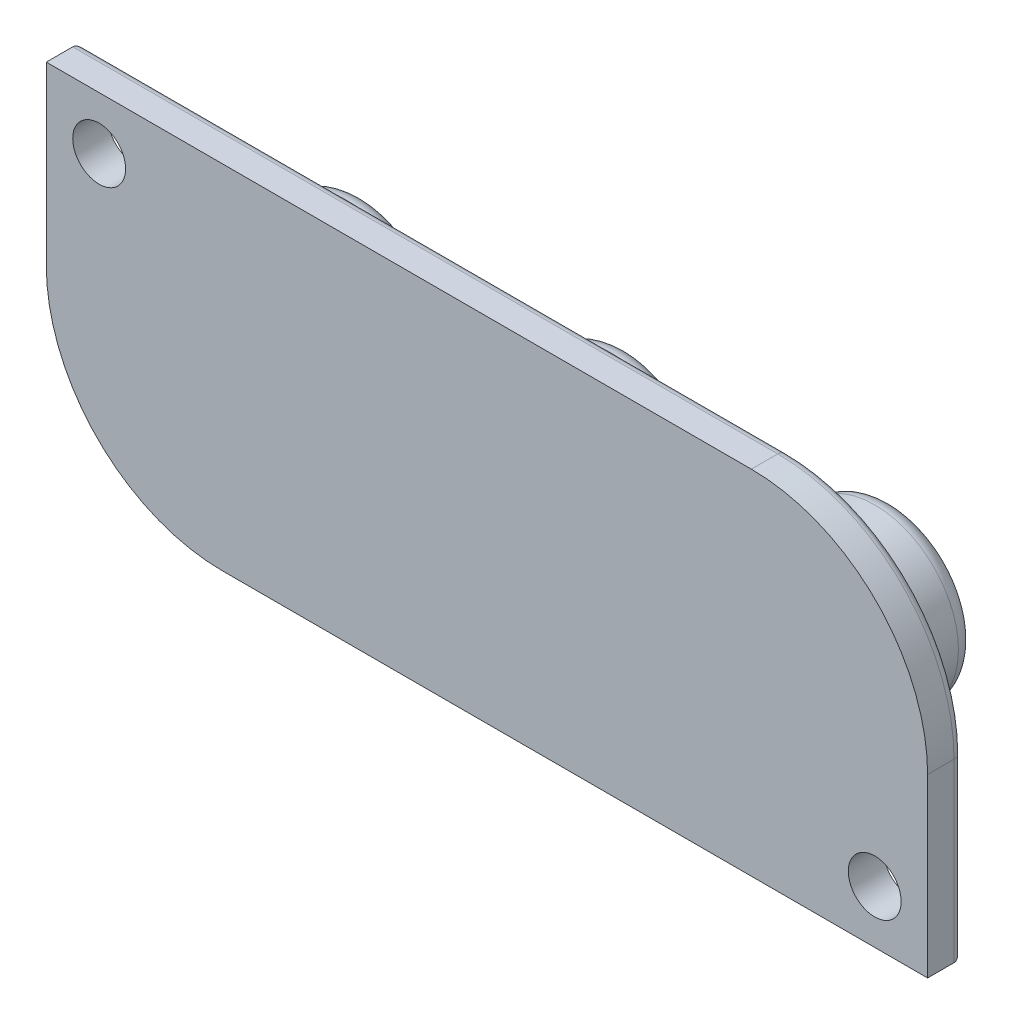
from build123d import *

# Parameters (mm, degrees)
CROQUIS1_W              = 50
CROQUIS1_H              = 20
SALIENTE_EXTRUIR1_DEPTH = 2
CROQUIS2_R              = 4.75
SALIENTE_EXTRUIR2_DEPTH = 6
REDONDEO1_R             = 10
CROQUIS10_R             = 1.5
CORTAR_EXTRUIR5_DEPTH   = 2
SALIENTE_EXTRUIR4_DEPTH = 0.5
REDONDEO2_R             = 2
REDONDEO3_R             = 0.5
REDONDEO4_R             = 1


with BuildPart() as part:
    # Croquis1 → Saliente-Extruir1 (new body)
    with BuildSketch(Plane.XY):
        with Locations((77.5, 27.5)):
            Rectangle(CROQUIS1_W, CROQUIS1_H)
    extrude(amount=SALIENTE_EXTRUIR1_DEPTH)

    # Croquis2 → Saliente-Extruir2 (add)
    with BuildSketch(Plane(origin=(0, 0, 0), x_dir=(-1, 0, 0), z_dir=(0, 0, -1))):
        with Locations((-92.5, 27.5)):
            Circle(CROQUIS2_R)
        with Locations((-77.5, 27.5)):
            Circle(CROQUIS2_R)
        with Locations((-62.5, 27.5)):
            Circle(CROQUIS2_R)
    extrude(amount=SALIENTE_EXTRUIR2_DEPTH)

    # Redondeo1
    redondeo1_edges = [part.edges().sort_by_distance(p)[0] for p in [
        (52.5, 17.5, 1),
        (102.5, 37.5, 1),
    ]]
    fillet(redondeo1_edges, radius=REDONDEO1_R)

    # Croquis10 → Cortar-Extruir5 (cut)
    with BuildSketch(Plane.XY.offset(2)):
        with Locations((99.5, 20.5)):
            Circle(CROQUIS10_R)
        with Locations((55.5, 34.5)):
            Circle(CROQUIS10_R)
    extrude(amount=-CORTAR_EXTRUIR5_DEPTH, mode=Mode.SUBTRACT)

    # Croquis12 → Saliente-Extruir4 (add)
    with BuildSketch(Plane(origin=(0, 0, -6), x_dir=(-1, 0, 0), z_dir=(0, 0, -1))):
        Polygon((-65.728582378, 27.617760721), (-60.958012758, 29.751858822), (-60.314223201, 29.111036038), (-62.427553897, 24.327610405), (-63.076288074, 24.974366734), (-62.488867188, 26.212499645), (-63.868416239, 27.587104075), (-65.104571302, 26.995727493), align=None)
        Polygon((-61.24183396, 28.848971164), (-63.245394087, 27.882792367), (-62.190212125, 26.830577177), (-61.2270001, 28.834137303), align=None, mode=Mode.SUBTRACT)
        with BuildLine():
            Line((-80.194104158, 27.217246481), (-76.74968169, 30.673536038))
            Line((-76.74968169, 30.673536038), (-75.069499728, 28.99928762))
            add(Edge.make_bspline(
                [(-75.069499728, 28.99928762), (-75.031406907, 28.959869805), (-74.957198808, 28.883080504), (-74.85725848, 28.763013024), (-74.769481382, 28.643121267), (-74.694794468, 28.522404001), (-74.634041008, 28.400607841), (-74.587719334, 28.278103073), (-74.552006431, 28.155992502), (-74.531457849, 28.033206264), (-74.524003268, 27.911119096), (-74.532026735, 27.790867413), (-74.554624799, 27.672672956), (-74.594577171, 27.557415166), (-74.646430642, 27.442885428), (-74.715918443, 27.332359673), (-74.798529925, 27.222991059), (-74.863080561, 27.155308069), (-74.896438019, 27.120331924)],
                knots=[0, 0, 0, 0, 0.000164402, 0.00032027, 0.000468229, 0.000609853, 0.000745627, 0.000875843, 0.001002309, 0.001126682, 0.001248516, 0.001368437, 0.001487326, 0.001608351, 0.001733574, 0.001863666, 0.001999152, 0.002144039, 0.002144039, 0.002144039, 0.002144039], degree=3))
            add(Edge.make_bspline(
                [(-74.896438019, 27.120331924), (-74.939852018, 27.079463327), (-75.023797155, 27.000439971), (-75.164643934, 26.906226208), (-75.310808548, 26.836820345), (-75.463612719, 26.79366792), (-75.621895796, 26.775903113), (-75.78562761, 26.783249402), (-75.955083291, 26.816604384), (-76.06613128, 26.856418859), (-76.123692766, 26.877056607)],
                knots=[0, 0, 0, 0, 0.000178623, 0.000345385, 0.000505975, 0.000662191, 0.000819451, 0.000981783, 0.001152067, 0.001335325, 0.001335325, 0.001335325, 0.001335325], degree=3))
            Line((-76.123692766, 26.877056607), (-76.133582006, 26.867167367))
            add(Edge.make_bspline(
                [(-76.133582006, 26.867167367), (-76.11369622, 26.834790241), (-76.074673108, 26.771254599), (-76.024712839, 26.673453892), (-75.986460519, 26.574768218), (-75.955922132, 26.477192217), (-75.9375611, 26.379250027), (-75.927133374, 26.282317931), (-75.927382868, 26.18523505), (-75.936778042, 26.088309081), (-75.958573722, 25.991919081), (-75.987753069, 25.89564402), (-76.028257606, 25.800481135), (-76.076554674, 25.704739447), (-76.136522338, 25.609945597), (-76.205809116, 25.515348193), (-76.284232508, 25.420382704), (-76.342784715, 25.360296437), (-76.372901626, 25.329390468)],
                knots=[0, 0, 0, 0, 0.000113971, 0.000223653, 0.000328879, 0.000431179, 0.000529898, 0.000627316, 0.000723241, 0.000820659, 0.000918807, 0.001019216, 0.001122064, 0.001228652, 0.001340606, 0.001458101, 0.001580288, 0.001709701, 0.001709701, 0.001709701, 0.001709701], degree=3))
            add(Edge.make_bspline(
                [(-76.372901626, 25.329390468), (-76.408461875, 25.29528593), (-76.47821672, 25.228386602), (-76.59264877, 25.143795796), (-76.70985266, 25.072500255), (-76.831291433, 25.016703203), (-76.956427812, 24.975928607), (-77.085482321, 24.950041076), (-77.21830116, 24.938620269), (-77.307764218, 24.943317011), (-77.352925361, 24.945687936)],
                knots=[0, 0, 0, 0, 0.000147681, 0.000289691, 0.000425879, 0.000558631, 0.000689666, 0.000819803, 0.000952764, 0.001088304, 0.001088304, 0.001088304, 0.001088304], degree=3))
            add(Edge.make_bspline(
                [(-77.352925361, 24.945687936), (-77.404574561, 24.951670485), (-77.509103747, 24.963778145), (-77.6645096, 25.006091539), (-77.820257286, 25.065947907), (-77.976931065, 25.143813749), (-78.134781623, 25.23927965), (-78.292653112, 25.353624165), (-78.451814459, 25.485549908), (-78.553479056, 25.584139987), (-78.605892133, 25.634968)],
                knots=[0, 0, 0, 0, 0.000155799, 0.00031531, 0.000481523, 0.000655776, 0.000839452, 0.00103431, 0.001240066, 0.001459029, 0.001459029, 0.001459029, 0.001459029], degree=3))
            Line((-78.605892133, 25.634968), (-80.194104158, 27.217246481))
        make_face()
        with BuildLine():
            Line((-78.020449095, 28.187380974), (-79.097387386, 27.107475911))
            Line((-79.097387386, 27.107475911), (-78.027371563, 26.041415784))
            add(Edge.make_bspline(
                [(-78.027371563, 26.041415784), (-78.003692834, 26.018242129), (-77.957888215, 25.973414534), (-77.884787626, 25.915056154), (-77.813013156, 25.864465073), (-77.741467308, 25.82221442), (-77.669705624, 25.789640552), (-77.598530707, 25.764053831), (-77.526916019, 25.7493305), (-77.455907848, 25.743586742), (-77.385043333, 25.744837015), (-77.31453407, 25.75768903), (-77.243983915, 25.77704161), (-77.174211174, 25.806482022), (-77.104812837, 25.844008761), (-77.036296808, 25.891605417), (-76.96688198, 25.946401409), (-76.923357209, 25.988910844), (-76.900987069, 26.010759139)],
                knots=[0, 0, 0, 0, 9.9336e-05, 0.000192158, 0.000280223, 0.000362654, 0.000440979, 0.000516352, 0.000589083, 0.000659547, 0.000729788, 0.000800998, 0.000873944, 0.000948874, 0.001027641, 0.001110203, 0.001198854, 0.001292598, 0.001292598, 0.001292598, 0.001292598], degree=3))
            add(Edge.make_bspline(
                [(-76.900987069, 26.010759139), (-76.879808073, 26.032478317), (-76.838632428, 26.074704169), (-76.785474447, 26.142242993), (-76.740091453, 26.209676479), (-76.704692869, 26.278300266), (-76.676411136, 26.34658383), (-76.657276966, 26.415635707), (-76.647378142, 26.485090242), (-76.646244482, 26.554907426), (-76.654729219, 26.624848047), (-76.670341325, 26.695295789), (-76.695376198, 26.765957898), (-76.729862897, 26.836275415), (-76.770999509, 26.908178467), (-76.823535062, 26.978797828), (-76.882378271, 27.051597043), (-76.927290902, 27.097610995), (-76.950433272, 27.121320848)],
                knots=[0, 0, 0, 0, 9.0949e-05, 0.00017682, 0.000257458, 0.000334423, 0.000408063, 0.000478839, 0.000548766, 0.000617998, 0.000687673, 0.000759648, 0.000834087, 0.000911936, 0.000994367, 0.001082198, 0.001175645, 0.001274981, 0.001274981, 0.001274981, 0.001274981], degree=3))
            Line((-76.950433272, 27.121320848), (-78.020449095, 28.187380974))
        make_face(mode=Mode.SUBTRACT)
        with BuildLine():
            Line((-76.635955424, 29.576819265), (-77.586311436, 28.623496481))
            Line((-77.586311436, 28.623496481), (-76.59837631, 27.63951705))
            add(Edge.make_bspline(
                [(-76.59837631, 27.63951705), (-76.561613064, 27.605410197), (-76.490405309, 27.539347684), (-76.367723814, 27.467152773), (-76.240731691, 27.417591371), (-76.13029606, 27.398873724), (-76.041778589, 27.399132549), (-75.976304774, 27.405620398), (-75.91198445, 27.421015661), (-75.84925073, 27.443483484), (-75.787782628, 27.474042972), (-75.727572252, 27.511421673), (-75.668780442, 27.557416206), (-75.632216186, 27.592692523), (-75.613407955, 27.610838253)],
                knots=[0, 0, 0, 0, 0.000150063, 0.00029066, 0.000424, 0.000557314, 0.000623572, 0.000689207, 0.000754213, 0.000821468, 0.000888693, 0.000959764, 0.001033749, 0.001112118, 0.001112118, 0.001112118, 0.001112118], degree=3))
            add(Edge.make_bspline(
                [(-75.613407955, 27.610838253), (-75.577668041, 27.649570472), (-75.510273372, 27.722607722), (-75.435968576, 27.844923514), (-75.390976397, 27.968344839), (-75.379750616, 28.094693465), (-75.400796761, 28.221450711), (-75.45345368, 28.347993989), (-75.536972318, 28.474431834), (-75.609468209, 28.551732597), (-75.648020297, 28.592839835)],
                knots=[0, 0, 0, 0, 0.000157785, 0.000297535, 0.000426392, 0.000548515, 0.000673703, 0.000808127, 0.000956795, 0.001125647, 0.001125647, 0.001125647, 0.001125647], degree=3))
            Line((-75.648020297, 28.592839835), (-76.635955424, 29.576819265))
        make_face(mode=Mode.SUBTRACT)
        with BuildLine():
            Line((-90.685693514, 26.645648379), (-91.290915033, 27.24889205))
            add(Edge.make_bspline(
                [(-91.290915033, 27.24889205), (-91.270582788, 27.284201993), (-91.230813835, 27.353266645), (-91.181685871, 27.459729499), (-91.140646572, 27.564217123), (-91.110026776, 27.667534568), (-91.087815863, 27.769301673), (-91.074768781, 27.869874732), (-91.071616725, 27.969263518), (-91.078817729, 28.066936619), (-91.094778839, 28.163222263), (-91.119166003, 28.258507454), (-91.154621319, 28.351822291), (-91.197800924, 28.444226251), (-91.252075773, 28.534299637), (-91.31455063, 28.623745845), (-91.38662045, 28.71171996), (-91.440488341, 28.767268784), (-91.467932438, 28.795569265)],
                knots=[0, 0, 0, 0, 0.000122179, 0.000238977, 0.000351371, 0.000458691, 0.000561881, 0.000663567, 0.000762504, 0.000859665, 0.000956887, 0.00105499, 0.001154184, 0.001255928, 0.001360572, 0.001469214, 0.001583048, 0.001701277, 0.001701277, 0.001701277, 0.001701277], degree=3))
            add(Edge.make_bspline(
                [(-91.467932438, 28.795569265), (-91.511194221, 28.836529053), (-91.595486332, 28.916335911), (-91.734705657, 29.015736435), (-91.878644099, 29.096140789), (-92.029219567, 29.154622136), (-92.18502764, 29.193708834), (-92.346187137, 29.212444863), (-92.513071547, 29.210687732), (-92.624449343, 29.193821026), (-92.681342248, 29.185205341)],
                knots=[0, 0, 0, 0, 0.000178547, 0.000347884, 0.000511655, 0.000671976, 0.000830996, 0.0009923, 0.001157462, 0.001329924, 0.001329924, 0.001329924, 0.001329924], degree=3))
            add(Edge.make_bspline(
                [(-92.681342248, 29.185205341), (-92.731688699, 29.174605566), (-92.832970013, 29.153282132), (-92.981745611, 29.103808089), (-93.128324244, 29.041127455), (-93.273375115, 28.965801407), (-93.416119044, 28.875935146), (-93.557556185, 28.773298289), (-93.69629142, 28.655835202), (-93.785119308, 28.570269196), (-93.830471995, 28.526581924)],
                knots=[0, 0, 0, 0, 0.00015425, 0.000310303, 0.000469372, 0.000632145, 0.000800076, 0.000974937, 0.001156005, 0.001344892, 0.001344892, 0.001344892, 0.001344892], degree=3))
            add(Edge.make_bspline(
                [(-93.830471995, 28.526581924), (-93.874299585, 28.481344137), (-93.96016923, 28.392711548), (-94.075681621, 28.252325122), (-94.179436236, 28.111506763), (-94.267221713, 27.967322008), (-94.343326254, 27.822281201), (-94.405756177, 27.67530406), (-94.453969479, 27.525936108), (-94.475443521, 27.42480602), (-94.48612864, 27.374485405)],
                knots=[0, 0, 0, 0, 0.000188887, 0.000370079, 0.00054494, 0.00071319, 0.000875964, 0.001035944, 0.001191692, 0.001345942, 0.001345942, 0.001345942, 0.001345942], degree=3))
            add(Edge.make_bspline(
                [(-94.48612864, 27.374485405), (-94.494452105, 27.317580367), (-94.510751953, 27.206143184), (-94.511020389, 27.039354925), (-94.493041987, 26.878006092), (-94.452385348, 26.722810491), (-94.394135977, 26.572232928), (-94.312510478, 26.429124314), (-94.213380745, 26.289576414), (-94.13352285, 26.205312057), (-94.092536868, 26.162064519)],
                knots=[0, 0, 0, 0, 0.00017234, 0.000337493, 0.000498797, 0.00065806, 0.000817461, 0.000981711, 0.001151048, 0.001329595, 0.001329595, 0.001329595, 0.001329595], degree=3))
            add(Edge.make_bspline(
                [(-94.092536868, 26.162064519), (-94.060126396, 26.131426446), (-93.996745113, 26.071511232), (-93.89399339, 25.994057881), (-93.788074653, 25.928810011), (-93.677356586, 25.878847593), (-93.564150943, 25.838959493), (-93.446369009, 25.815199833), (-93.325460281, 25.80096894), (-93.243744635, 25.8036898), (-93.202505223, 25.805062936)],
                knots=[0, 0, 0, 0, 0.00013371, 0.00026148, 0.000385289, 0.000506092, 0.000625244, 0.000744527, 0.000865859, 0.000989478, 0.000989478, 0.000989478, 0.000989478], degree=3))
            add(Edge.make_bspline(
                [(-93.202505223, 25.805062936), (-93.164180217, 25.808326331), (-93.087699662, 25.814838692), (-92.9737791, 25.837160931), (-92.860887833, 25.870306547), (-92.748051791, 25.912366857), (-92.63656614, 25.966674081), (-92.526079975, 26.031124859), (-92.415878047, 26.105249665), (-92.345398649, 26.16124076), (-92.309506805, 26.189754392)],
                knots=[0, 0, 0, 0, 0.000115327, 0.000230145, 0.000347511, 0.000468001, 0.000590962, 0.000719023, 0.000851502, 0.000988977, 0.000988977, 0.000988977, 0.000988977], degree=3))
            Line((-92.309506805, 26.189754392), (-91.718130223, 25.600355658))
            add(Edge.make_bspline(
                [(-91.718130223, 25.600355658), (-91.772972311, 25.553412854), (-91.880646783, 25.461247479), (-92.054183568, 25.344504773), (-92.22911169, 25.24298529), (-92.409726041, 25.162721963), (-92.593976904, 25.099995543), (-92.782428411, 25.055960234), (-92.975033443, 25.032825508), (-93.169744559, 25.026206281), (-93.364093447, 25.040690174), (-93.555107501, 25.071763675), (-93.740897231, 25.123314208), (-93.920757349, 25.195881468), (-94.096380797, 25.284651732), (-94.266294903, 25.393279817), (-94.430350475, 25.521699584), (-94.532727115, 25.618927468), (-94.585021045, 25.668591417)],
                knots=[0, 0, 0, 0, 0.000216396, 0.000424862, 0.000626394, 0.000822495, 0.0010167, 0.001209568, 0.0014019, 0.001597797, 0.001793107, 0.001985599, 0.002177545, 0.002370182, 0.00256655, 0.00276709, 0.002974212, 0.003190479, 0.003190479, 0.003190479, 0.003190479], degree=3))
            add(Edge.make_bspline(
                [(-94.585021045, 25.668591417), (-94.645113638, 25.731315989), (-94.762768419, 25.854123901), (-94.912021768, 26.05570633), (-95.037233506, 26.263276005), (-95.135853997, 26.479255802), (-95.208407046, 26.702928919), (-95.255209808, 26.934084824), (-95.275725437, 27.173138802), (-95.268220109, 27.33426432), (-95.264411868, 27.416020215)],
                knots=[0, 0, 0, 0, 0.000260371, 0.000509778, 0.000750609, 0.000986483, 0.001220409, 0.0014545, 0.001692665, 0.00193799, 0.00193799, 0.00193799, 0.00193799], degree=3))
            add(Edge.make_bspline(
                [(-95.264411868, 27.416020215), (-95.256780963, 27.494382278), (-95.241592663, 27.650351522), (-95.190416338, 27.879575515), (-95.120483561, 28.103744925), (-95.02699161, 28.32153589), (-94.911291137, 28.533460176), (-94.773679663, 28.739101697), (-94.617134586, 28.941497527), (-94.496907228, 29.066288379), (-94.435693514, 29.129825594)],
                knots=[0, 0, 0, 0, 0.000236005, 0.000469737, 0.00070306, 0.00093965, 0.001179503, 0.001426354, 0.001681354, 0.001945861, 0.001945861, 0.001945861, 0.001945861], degree=3))
            add(Edge.make_bspline(
                [(-94.435693514, 29.129825594), (-94.371630317, 29.19112322), (-94.245873767, 29.311450933), (-94.04558347, 29.472226539), (-93.839068375, 29.610492353), (-93.626662558, 29.72679747), (-93.408680841, 29.821564308), (-93.184484124, 29.892371961), (-92.955352483, 29.944875995), (-92.799278603, 29.959899533), (-92.72089921, 29.967444265)],
                knots=[0, 0, 0, 0, 0.000265905, 0.000521973, 0.000769372, 0.001010566, 0.001247547, 0.00148117, 0.001715113, 0.001951118, 0.001951118, 0.001951118, 0.001951118], degree=3))
            add(Edge.make_bspline(
                [(-92.72089921, 29.967444265), (-92.639473874, 29.971252669), (-92.479008395, 29.978757918), (-92.240599719, 29.958215293), (-92.010267969, 29.911307856), (-91.786618332, 29.83998431), (-91.570990014, 29.740899686), (-91.362661006, 29.616420769), (-91.161307718, 29.466743689), (-91.038231114, 29.34972429), (-90.975448261, 29.290031291)],
                knots=[0, 0, 0, 0, 0.000244336, 0.000481515, 0.000715606, 0.000948287, 0.001184162, 0.001425842, 0.001675249, 0.001934952, 0.001934952, 0.001934952, 0.001934952], degree=3))
            add(Edge.make_bspline(
                [(-90.975448261, 29.290031291), (-90.927523774, 29.240636047), (-90.833728064, 29.143961835), (-90.708548386, 28.989143785), (-90.598600573, 28.831257487), (-90.504275048, 28.66959064), (-90.425011673, 28.504480647), (-90.363502177, 28.334958926), (-90.314073174, 28.162390089), (-90.296132119, 28.044576576), (-90.287157121, 27.985640468)],
                knots=[0, 0, 0, 0, 0.000206382, 0.000403922, 0.000596498, 0.000783072, 0.000964876, 0.001145093, 0.001323594, 0.001502272, 0.001502272, 0.001502272, 0.001502272], degree=3))
            add(Edge.make_bspline(
                [(-90.287157121, 27.985640468), (-90.281302599, 27.924721121), (-90.269766622, 27.804683301), (-90.274077752, 27.625250994), (-90.297002717, 27.450311675), (-90.33762057, 27.279574297), (-90.396405113, 27.113060742), (-90.474068848, 26.951370915), (-90.570442512, 26.79410071), (-90.646817987, 26.695723107), (-90.685693514, 26.645648379)],
                knots=[0, 0, 0, 0, 0.000183474, 0.000361524, 0.000537055, 0.000711916, 0.00088707, 0.00106577, 0.001249116, 0.001439187, 0.001439187, 0.001439187, 0.001439187], degree=3))
        make_face()
    extrude(amount=SALIENTE_EXTRUIR4_DEPTH)

    # Redondeo2
    redondeo2_edges = [part.edges().sort_by_distance(p)[0] for p in [
        (97.25, 27.5, 0),
        (82.25, 27.5, 0),
        (67.25, 27.5, 0),
    ]]
    fillet(redondeo2_edges, radius=REDONDEO2_R)

    # Redondeo3
    redondeo3_edges = [part.edges().sort_by_distance(p)[0] for p in [
        (72.5, 37.5, 0),
        (82.5, 17.5, 0),
        (55.428932188, 20.428932188, 0),
        (99.571067812, 34.571067812, 0),
        (52.5, 32.5, 0),
        (102.5, 22.5, 0),
    ]]
    fillet(redondeo3_edges, radius=REDONDEO3_R)

    # Redondeo4
    redondeo4_edges = [part.edges().sort_by_distance(p)[0] for p in [
        (97.25, 27.5, -6),
        (82.25, 27.5, -6),
        (67.25, 27.5, -6),
    ]]
    fillet(redondeo4_edges, radius=REDONDEO4_R)


solid = part.part
